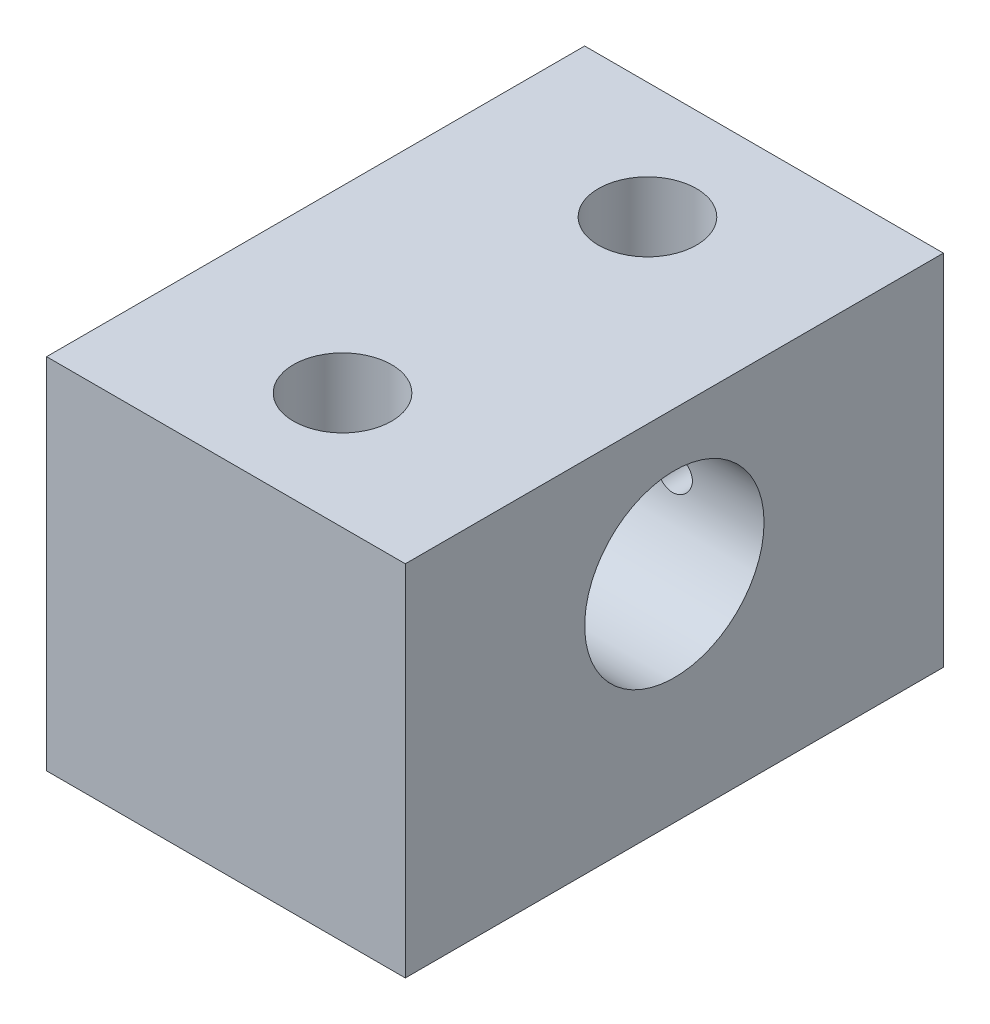
from build123d import *

# Parameters (mm, degrees)
SKETCH1_W                    = 50.8
SKETCH1_H                    = 50.8
EXTRUDE1_DEPTH               = 38.1
SKETCH2_R                    = 12.7
EXTRUDE2_DEPTH               = 69.391593051
F_1_2_CLEARANCE_HOLE1_D      = 13.89126
F_1_4_20_TAPPED_HOLE1_REACH  = 92.482
F_1_4_20_TAPPED_HOLE1_BORE_R = 2.5527


with BuildPart() as part:
    # Sketch1 → Extrude1 (new, symmetric)
    with BuildSketch(Plane.XY):
        Rectangle(SKETCH1_W, SKETCH1_H)
    extrude(amount=EXTRUDE1_DEPTH, both=True)

    # Sketch2 → Extrude2 (cut, through all)
    with BuildSketch(Plane(origin=(25.4, 0, 0), x_dir=(0, 0, -1), z_dir=(1, 0, 0))):
        with Locations((0, 5.08)):
            Circle(SKETCH2_R)
    extrude(amount=-EXTRUDE2_DEPTH, mode=Mode.SUBTRACT)

    # 1/2 Clearance Hole1 (through all)
    with Locations(Plane(origin=(0, 25.4, 21.59), x_dir=(0, 0, 1), z_dir=(0, 1, 0))):
        with Locations((0, 0)):
            f_1_2_clearance_hole1 = Hole(F_1_2_CLEARANCE_HOLE1_D / 2)

    # Mirror1: 1/2 Clearance Hole1 across plane
    add(f_1_2_clearance_hole1.mirror(Plane.XY), mode=Mode.SUBTRACT)

    # 1/4-20 Tapped Hole1 bore (on position points) → 1/4-20 Tapped Hole1 (cut, up to next)
    with BuildSketch(Plane(origin=(12.7, 5.08, -38.1), x_dir=(-1, 0, 0), z_dir=(0, 0, -1)), mode=Mode.PRIVATE) as f_1_4_20_tapped_hole1_sk1:
        Circle(F_1_4_20_TAPPED_HOLE1_BORE_R)
    f_1_4_20_tapped_hole1_tool1 = extrude(f_1_4_20_tapped_hole1_sk1.sketch, amount=-F_1_4_20_TAPPED_HOLE1_REACH, mode=Mode.PRIVATE) & part.part
    f_1_4_20_tapped_hole1 = f_1_4_20_tapped_hole1_tool1.solids().sort_by_distance((12.7, 5.08, -38.1))[0]
    add(f_1_4_20_tapped_hole1, mode=Mode.SUBTRACT)

    # Mirror2: 1/4-20 Tapped Hole1 across plane
    add(f_1_4_20_tapped_hole1.mirror(Plane(origin=(0, 0, 0), x_dir=(0, 0, 1), z_dir=(1, 0, 0))), mode=Mode.SUBTRACT)


solid = part.part
